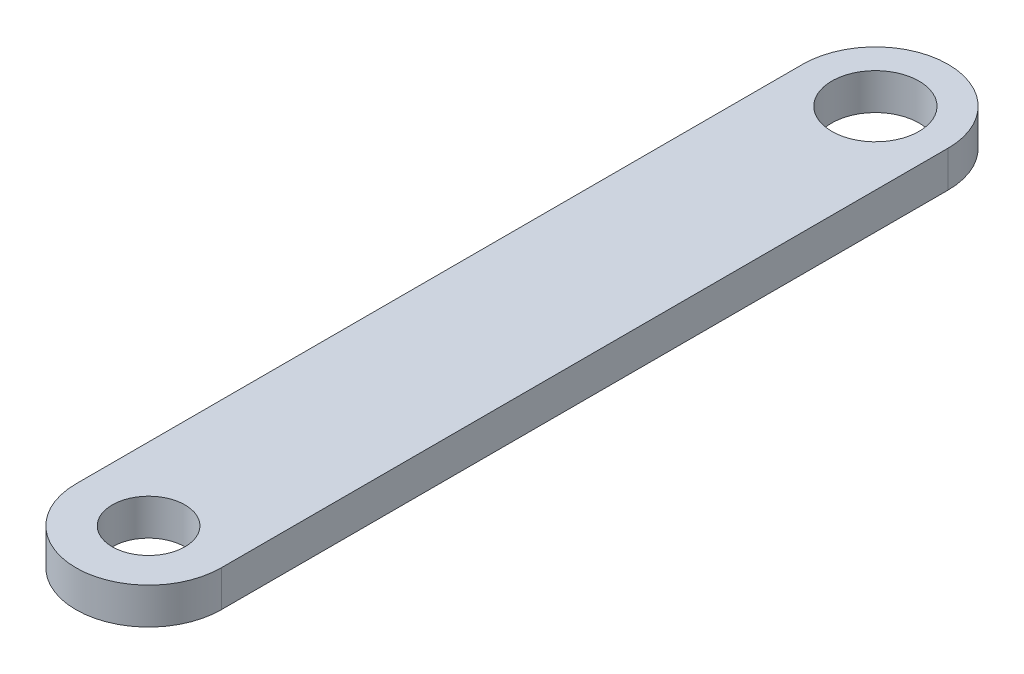
from build123d import *

# Parameters (mm, degrees)
SKETCH1_R           = 6
SKETCH1_R_2         = 5
BOSS_EXTRUDE1_DEPTH = 5


with BuildPart() as part:
    # Sketch1 → Boss-Extrude1 (new body)
    with BuildSketch(Plane(origin=(0, 0, 0), x_dir=(1, 0, 0), z_dir=(0, 1, 0))):
        with BuildLine():
            Line((10, 0), (10, -100))
            ThreePointArc((10, -100), (0, -110), (-10, -100))
            Line((-10, -100), (-10, 0))
            ThreePointArc((-10, 0), (0, 10), (10, 0))
        make_face()
        Circle(SKETCH1_R, mode=Mode.SUBTRACT)
        with Locations((0, -100)):
            Circle(SKETCH1_R_2, mode=Mode.SUBTRACT)
    extrude(amount=BOSS_EXTRUDE1_DEPTH)


solid = part.part
